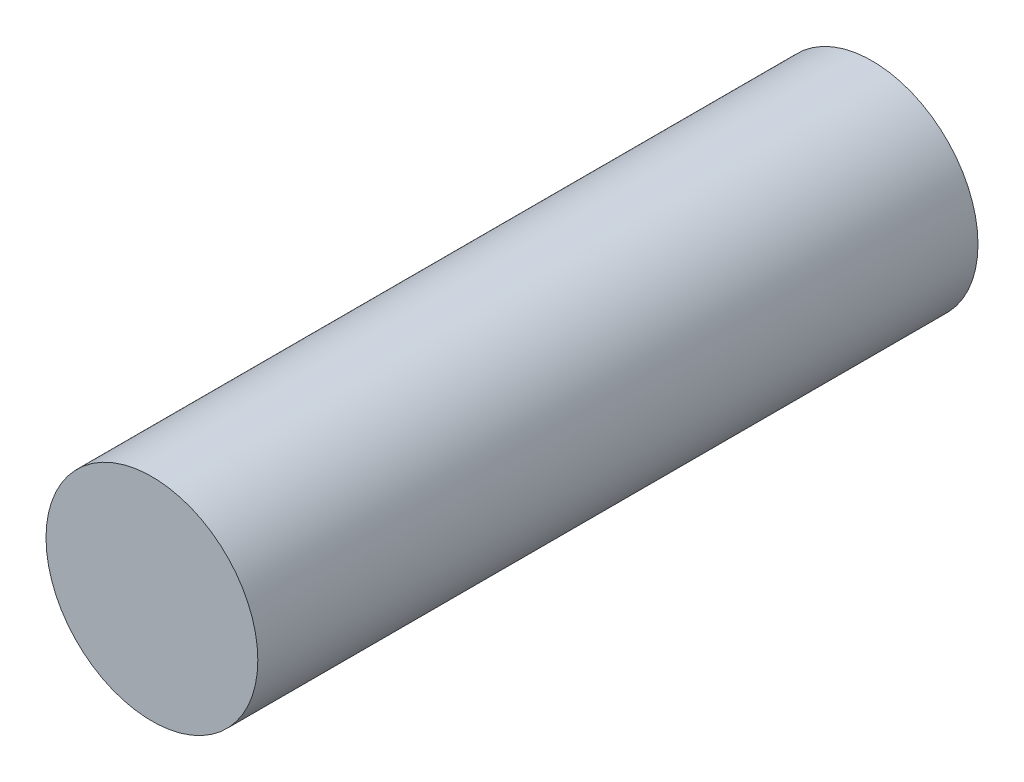
from build123d import *

# Parameters (mm, degrees)
SKETCH_1_R      = 2.5
EXTRUDE_1_DEPTH = 17


with BuildPart() as part:
    # Эскиз1 → Бобышка-Вытянуть1 (new body)
    with BuildSketch(Plane.XY):
        Circle(SKETCH_1_R)
    extrude(amount=EXTRUDE_1_DEPTH)


solid = part.part
